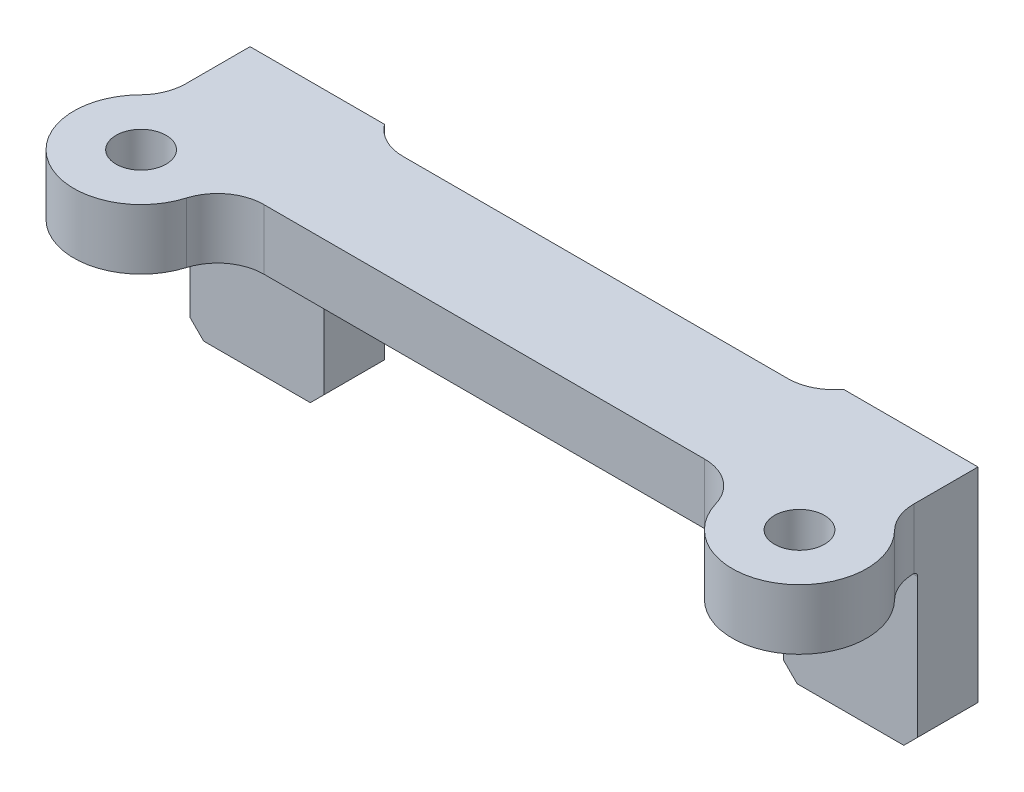
from build123d import *

# Parameters (mm, degrees)
BOSS_EXTRU_1_DEPTH           = 38
BOSS_EXTRU_1_DEPTH_BACK      = 10
ESQUISSE8_W                  = 200
ESQUISSE8_H                  = 45
ENL_V_MAT_EXTRU_4_DEPTH      = 34
TROU_TARAUD_M14X1_51_D       = 12.5
TROU_TARAUD_M14X1_51_DEPTH   = 17.5
TROU_TARAUD_M14X1_51_TIP     = 3.755378869
ESQUISSE10_W                 = 99
ESQUISSE10_H                 = 34
ENL_V_MAT_EXTRU_6_DEPTH      = 14
CONG_2_R                     = 10
ENL_V_MAT_EXTRU_7_DEPTH      = 1
ENL_V_MAT_EXTRU_7_DEPTH_BACK = 49
TROU_TARAUD_M12X1_251_D      = 10.8
CHANFREIN1_SIZE              = 3
CONG_3_R                     = 1
ESQUISSE14_W                 = 218.12810102
ESQUISSE14_H                 = 78.447864133
ENL_V_MAT_EXTRU_8_DEPTH      = 1


with BuildPart() as part:
    # Esquisse1 → Boss.-Extru.1 (new body, two sides)
    with BuildSketch(Plane(origin=(0, 0, 0), x_dir=(1, 0, 0), z_dir=(0, 1, 0))) as boss_extru_1_sk:
        with BuildLine():
            Line((-7.5, 31), (149.5, 31))
            Line((149.5, 31), (149.5, 17.146428199))
            ThreePointArc((149.5, 17.146428199), (150.241799002, 13.366783469), (152.357142857, 10.147886077))
            ThreePointArc((152.357142857, 10.147886077), (149.361144189, -12.492540023), (128.104434711, -4.142857143))
            ThreePointArc((128.104434711, -4.142857143), (124.497429283, 1.017837257), (118.521286236, 3))
            Line((118.521286236, 3), (23.478713764, 3))
            ThreePointArc((23.478713764, 3), (17.502570717, 1.017837257), (13.895565289, -4.142857143))
            ThreePointArc((13.895565289, -4.142857143), (-7.361144189, -12.492540023), (-10.357142857, 10.147886077))
            ThreePointArc((-10.357142857, 10.147886077), (-8.241799002, 13.366783469), (-7.5, 17.146428199))
            Line((-7.5, 17.146428199), (-7.5, 31))
        make_face()
    extrude(amount=BOSS_EXTRU_1_DEPTH)
    extrude(boss_extru_1_sk.sketch, amount=-BOSS_EXTRU_1_DEPTH_BACK)

    # Esquisse8 → Enlèv. mat.-Extru.4 (cut)
    with BuildSketch(Plane.XZ.offset(10)):
        with Locations((75, 4.5)):
            Rectangle(ESQUISSE8_W, ESQUISSE8_H)
    extrude(amount=-ENL_V_MAT_EXTRU_4_DEPTH, mode=Mode.SUBTRACT)

    # Trou taraudé M14x1.51
    with Locations(Plane(origin=(0, 0, -31), x_dir=(-1, 0, 0), z_dir=(0, 0, -1))):
        with Locations((-136, 19.5), (-6, 19.5)):
            Hole(TROU_TARAUD_M14X1_51_D / 2, depth=TROU_TARAUD_M14X1_51_DEPTH)
            with Locations((0, 0, -(TROU_TARAUD_M14X1_51_DEPTH + TROU_TARAUD_M14X1_51_TIP / 2))):  # 118° drill point
                Cone(0, TROU_TARAUD_M14X1_51_D / 2, TROU_TARAUD_M14X1_51_TIP, mode=Mode.SUBTRACT)

    # Esquisse10 → Enlèv. mat.-Extru.6 (cut, through all)
    with BuildSketch(Plane.XY.offset(-18)):
        with Locations((71, 7)):
            Rectangle(ESQUISSE10_W, ESQUISSE10_H)
    extrude(amount=-ENL_V_MAT_EXTRU_6_DEPTH, mode=Mode.SUBTRACT)

    # Congé2
    cong_2_edges = [part.edges().sort_by_distance(p)[0] for p in [
        (21.5, 24, -24.5),
        (120.5, 24, -24.5),
    ]]
    fillet(cong_2_edges, radius=CONG_2_R)

    # Esquisse11 → Enlèv. mat.-Extru.7 (cut, two sides)
    with BuildSketch(Plane(origin=(0, 38, 0), x_dir=(1, 0, 0), z_dir=(0, 1, 0))) as enl_v_mat_extru_7_sk:
        with BuildLine():
            Line((29.5, 27), (112.5, 27))
            ThreePointArc((112.5, 27), (119.571067812, 29.928932188), (122.5, 37))
            Line((122.5, 37), (122.5, 47))
            Line((122.5, 47), (19.5, 47))
            Line((19.5, 47), (19.5, 37))
            ThreePointArc((19.5, 37), (22.428932188, 29.928932188), (29.5, 27))
        make_face()
    extrude(amount=ENL_V_MAT_EXTRU_7_DEPTH, mode=Mode.SUBTRACT)
    extrude(enl_v_mat_extru_7_sk.sketch, amount=-ENL_V_MAT_EXTRU_7_DEPTH_BACK, mode=Mode.SUBTRACT)

    # Trou taraudé M12x1.251 (through all)
    with Locations(Plane(origin=(0, 24, 0), x_dir=(-1, 0, 0), z_dir=(0, -1, 0))):
        with Locations((0, 0), (-142, 0)):
            Hole(TROU_TARAUD_M12X1_251_D / 2)

    # Chanfrein1
    chanfrein1_edges = [part.edges().sort_by_distance(p)[0] for p in [
        (21.5, -10, -24.5),
        (120.5, -10, -24.5),
        (-7.5, -10, -24.5),
        (149.5, -10, -24.5),
    ]]
    chamfer(chanfrein1_edges, length=CHANFREIN1_SIZE)

    # Congé3
    cong_3_edges = [part.edges().sort_by_distance(p)[0] for p in [
        (144.918668947, 24, -18),
        (121.081331053, 24, -18),
        (20.918668947, 24, -18),
        (-2.918668947, 24, -18),
    ]]
    fillet(cong_3_edges, radius=CONG_3_R)

    # Esquisse14 → Enlèv. mat.-Extru.8 (cut)
    with BuildSketch(Plane(origin=(0, 38, 0), x_dir=(1, 0, 0), z_dir=(0, 1, 0))):
        with Locations((74.423535218, 6.641931997)):
            Rectangle(ESQUISSE14_W, ESQUISSE14_H)
    extrude(amount=-ENL_V_MAT_EXTRU_8_DEPTH, mode=Mode.SUBTRACT)


solid = part.part
